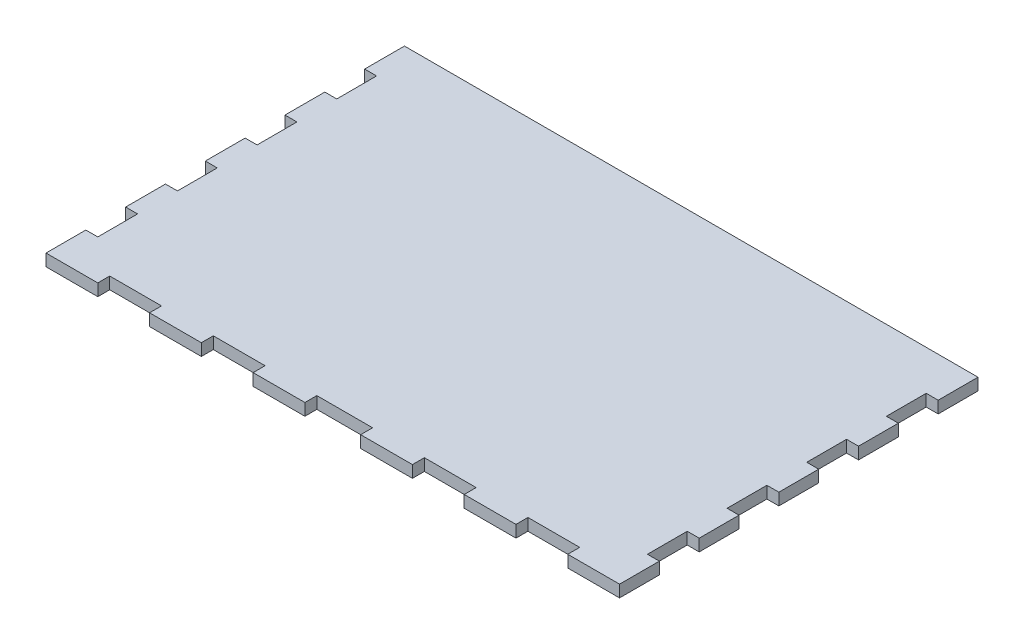
from build123d import *

# Parameters (mm, degrees)
BOSS_EXTRUDE2_DEPTH = 3


with BuildPart() as part:
    # Sketch1 → Boss-Extrude2 (new body)
    with BuildSketch(Plane(origin=(0, 0, 0), x_dir=(1, 0, 0), z_dir=(0, 1, 0))):
        Polygon((39, 90), (26, 90), (13, 90), (0, 90), (0, 80), (3, 80), (3, 70), (0, 70), (0, 60), (3, 60), (3, 50), (0, 50), (0, 40), (3, 40), (3, 30), (0, 30), (0, 20), (3, 20), (3, 10), (0, 10), (0, 0), (13, 0), (13, 3), (26, 3), (26, 0), (39, 0), (39, 3), (52, 3), (52, 0), (65, 0), (65, 3), (79, 3), (79, 0), (92, 0), (92, 3), (105, 3), (105, 0), (118, 0), (118, 3), (131, 3), (131, 0), (144, 0), (144, 10), (141, 10), (141, 20), (144, 20), (144, 30), (141, 30), (141, 40), (144, 40), (144, 50), (141, 50), (141, 60), (144, 60), (144, 70), (141, 70), (141, 80), (144, 80), (144, 90), (131, 90), (118, 90), (105, 90), (92, 90), (79, 90), (65, 90), (52, 90), align=None)
    extrude(amount=BOSS_EXTRUDE2_DEPTH)


solid = part.part
